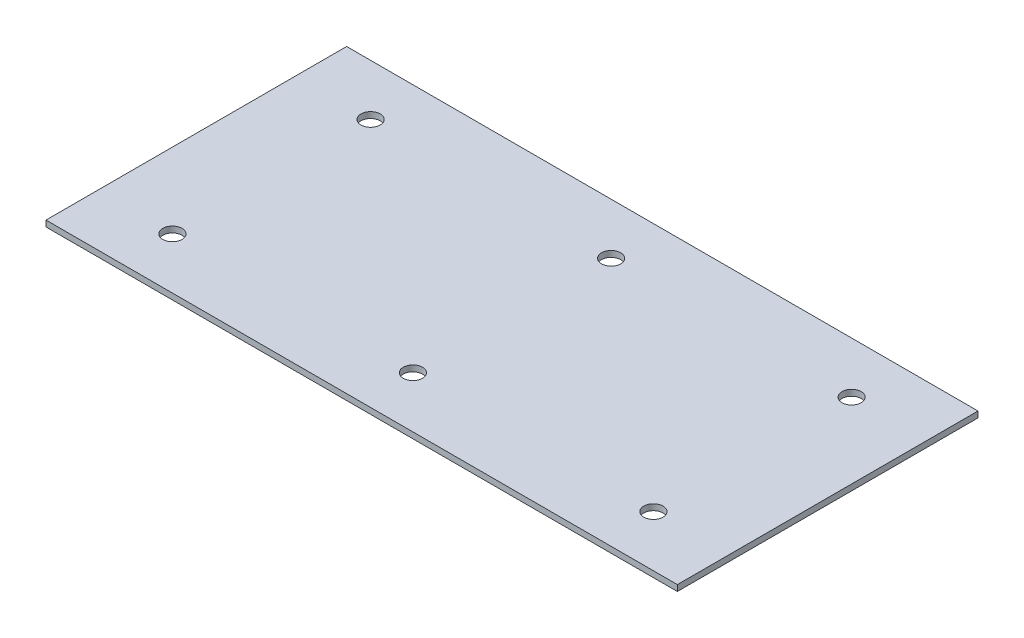
from build123d import *

# Parameters (mm, degrees)
SKETCH_1_W      = 210
SKETCH_1_H      = 100
SKETCH_1_R      = 3.2
EXTRUDE_1_DEPTH = 2


with BuildPart() as part:
    # Эскиз1 → Бобышка-Вытянуть1 (new body)
    with BuildSketch(Plane(origin=(0, 0, 0), x_dir=(1, 0, 0), z_dir=(0, 1, 0))):
        with Locations((105, 50)):
            Rectangle(SKETCH_1_W, SKETCH_1_H)
        with Locations((25, 17.034247801)):
            Circle(SKETCH_1_R, mode=Mode.SUBTRACT)
        with Locations((185, 17.034247801)):
            Circle(SKETCH_1_R, mode=Mode.SUBTRACT)
        with Locations((105, 17.034247801)):
            Circle(SKETCH_1_R, mode=Mode.SUBTRACT)
        with Locations((25, 82.965752199)):
            Circle(SKETCH_1_R, mode=Mode.SUBTRACT)
        with Locations((105, 82.965752199)):
            Circle(SKETCH_1_R, mode=Mode.SUBTRACT)
        with Locations((185, 82.965752199)):
            Circle(SKETCH_1_R, mode=Mode.SUBTRACT)
    extrude(amount=EXTRUDE_1_DEPTH)


solid = part.part
